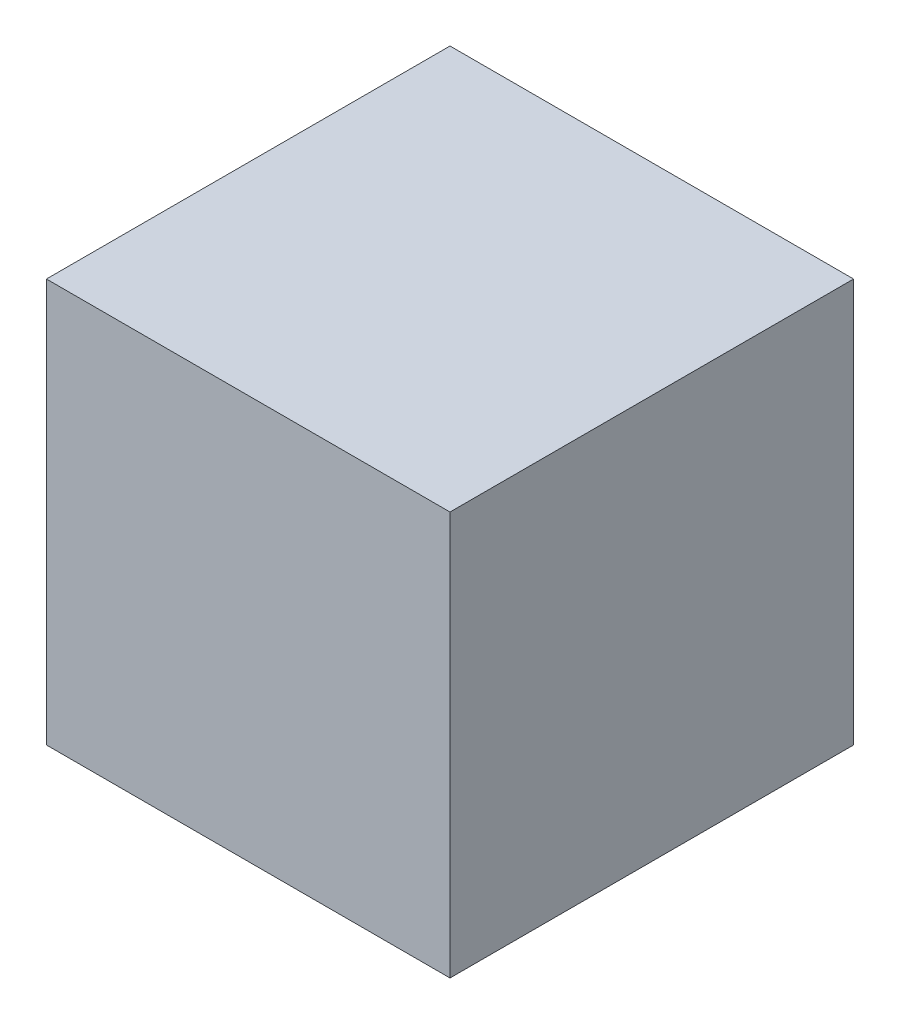
from build123d import *

# Parameters (mm, degrees)
SZKIC1_W                    = 35
SZKIC1_H                    = 35
DODANIE_WYCI_GNI_CIE1_DEPTH = 35


with BuildPart() as part:
    # Szkic1 → Dodanie-wyciągnięcie1 (new body)
    with BuildSketch(Plane.XY):
        Rectangle(SZKIC1_W, SZKIC1_H)
    extrude(amount=DODANIE_WYCI_GNI_CIE1_DEPTH)


solid = part.part
